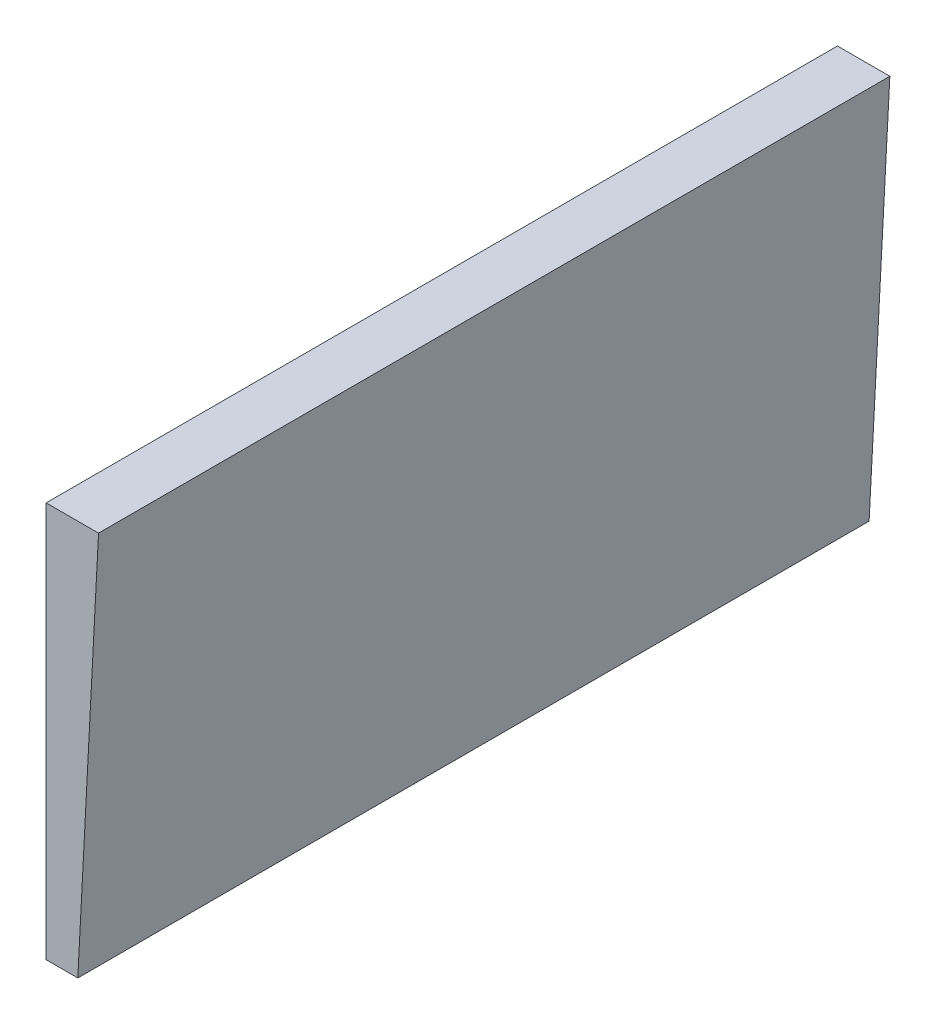
from build123d import *

# Parameters (mm, degrees)
BOSS_EXTRUDE1_DEPTH = 50


with BuildPart() as part:
    # Sketch1 → Boss-Extrude1 (new body)
    with BuildSketch(Plane.XY):
        Polygon((0, 0), (1.310194482, 25), (0, 25), (-2, 25), (-2, 0), align=None)
    extrude(amount=BOSS_EXTRUDE1_DEPTH)


solid = part.part
